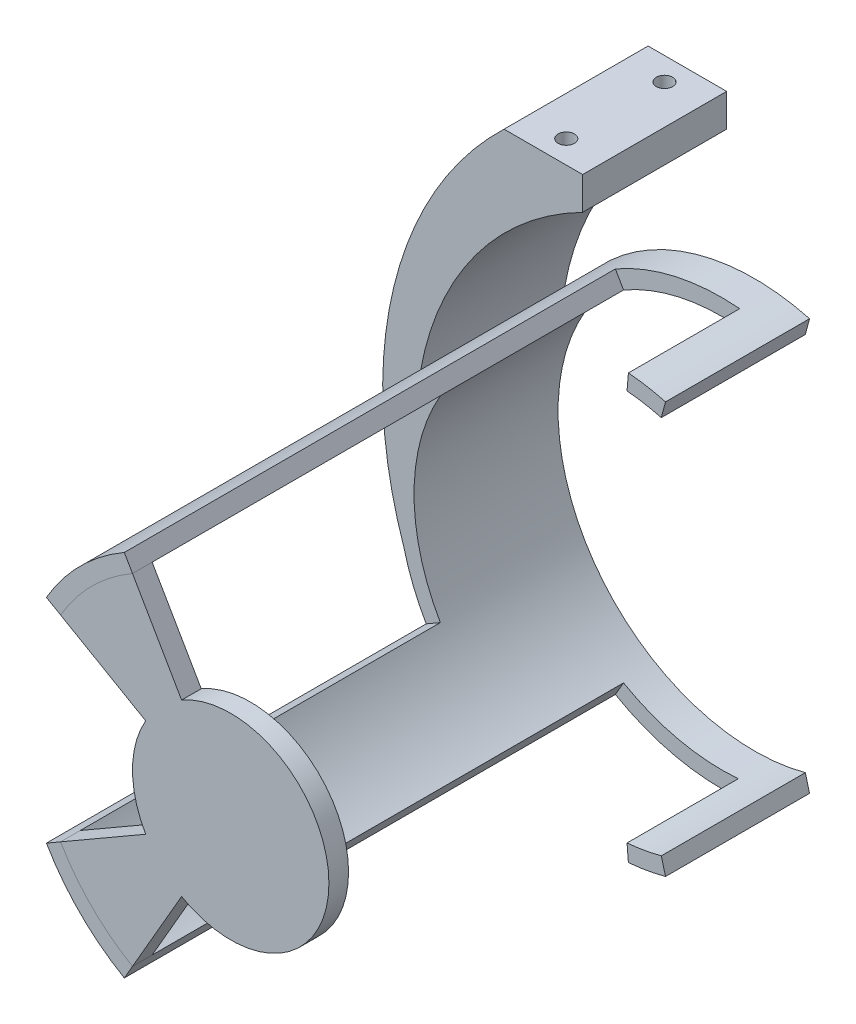
from build123d import *

# Parameters (mm, degrees)
ESQUISSE1_R                  = 32.5
ESQUISSE1_R_2                = 30
BOSS_EXTRU_1_DEPTH           = 22
BOSS_EXTRU_2_DEPTH           = 58
BOSS_EXTRU_3_START           = -77
BOSS_EXTRU_3_DEPTH           = 3
BOSS_EXTRU_4_DEPTH           = 22
ENL_V_MAT_EXTRU_1_DEPTH      = 22
ENL_V_START                  = -5
ENL_V_MAT_EXTRU_3_DEPTH      = 52
ESQUISSE9_R                  = 1.25
ENL_V_MAT_EXTRU_4_DEPTH      = 4
ENL_V_MAT_EXTRU_5_REACH      = 122.85
ENL_V_MAT_EXTRU_5_END_RADIUS = 46.665875386
ESQUISSE10_R                 = 2.5


with BuildPart() as part:
    # Esquisse1 → Boss.-Extru.1 (new body)
    with BuildSketch(Plane.XY):
        Circle(ESQUISSE1_R)
        Circle(ESQUISSE1_R_2, mode=Mode.SUBTRACT)
    extrude(amount=BOSS_EXTRU_1_DEPTH)

    # Esquisse2 → Boss.-Extru.2 (add)
    with BuildSketch(Plane.XY.offset(22)):
        with BuildLine():
            Line((-16.25, 28.145825623), (-15, 25.980762114))
            ThreePointArc((-15, 25.980762114), (-21.213203436, 21.213203436), (-25.980762114, 15))
            Line((-25.980762114, 15), (-28.145825623, 16.25))
            ThreePointArc((-28.145825623, 16.25), (-22.980970389, 22.980970389), (-16.25, 28.145825623))
        make_face()
        with BuildLine():
            Line((-28.145825623, -16.25), (-25.980762114, -15))
            ThreePointArc((-25.980762114, -15), (-21.213203436, -21.213203436), (-15, -25.980762114))
            Line((-15, -25.980762114), (-16.25, -28.145825623))
            ThreePointArc((-16.25, -28.145825623), (-22.980970389, -22.980970389), (-28.145825623, -16.25))
        make_face()
    extrude(amount=BOSS_EXTRU_2_DEPTH)

    # Esquisse5 → Boss.-Extru.4 (add)
    with BuildSketch(Plane(origin=(0, 0, 0), x_dir=(-1, 0, 0), z_dir=(0, 0, -1))):
        with BuildLine():
            Line((4.25, 50.131720502), (4.25, 55.131720502))
            Line((4.25, 55.131720502), (16.25, 55.131720502))
            ThreePointArc((16.25, 55.131720502), (33.096232565, 25.843443716), (31.523352961, -7.907478619))
            ThreePointArc((31.523352961, -7.907478619), (32.352628695, 3.091507158), (29.455329215, 13.734394083))
            ThreePointArc((29.455329215, 13.734394083), (21.443712719, 35.112380899), (4.25, 50.131720502))
        make_face()
    extrude(amount=-BOSS_EXTRU_4_DEPTH)

    # Esquisse6 → Enlèv. mat.-Extru.1 (cut)
    with BuildSketch(Plane(origin=(0, 0, 0), x_dir=(-1, 0, 0), z_dir=(0, 0, -1))):
        Polygon((0, 0), (-10.262824663, -38.301383073), (-52.320818682, 0), (-10.262824663, 38.301383073), align=None)
    extrude(amount=-ENL_V_MAT_EXTRU_1_DEPTH, mode=Mode.SUBTRACT)

    # Esquisse8 → Enlèv. mat.-Extru.3 (cut)
    with BuildSketch(Plane(origin=(0, 0, 0), x_dir=(-1, 0, 0), z_dir=(0, 0, -1)).offset(ENL_V_START)):
        with BuildLine():
            Line((-2.740791097, 32.384225545), (-1.521870682, 17.981889782))
            Line((-1.521870682, 17.981889782), (8.380077244, 14.514719558))
            Line((8.380077244, 14.514719558), (16.25, 28.145825623))
            ThreePointArc((16.25, 28.145825623), (7.079243588, 31.719620272), (-2.740791097, 32.384225545))
        make_face()
        with BuildLine():
            Line((-2.740791097, -32.384225545), (-1.521870682, -17.981889782))
            Line((-1.521870682, -17.981889782), (8.380077244, -14.514719558))
            Line((8.380077244, -14.514719558), (16.25, -28.145825623))
            ThreePointArc((16.25, -28.145825623), (7.079243588, -31.719620272), (-2.740791097, -32.384225545))
        make_face()
    extrude(amount=-ENL_V_MAT_EXTRU_3_DEPTH, mode=Mode.SUBTRACT)

    # Esquisse9 → Enlèv. mat.-Extru.4 (cut)
    with BuildSketch(Plane(origin=(0, 55.131720502, 0), x_dir=(1, 0, 0), z_dir=(0, 1, 0))):
        with Locations(Location((-10.25, -3.5, 0), (0, 0, 270))):
            Circle(ESQUISSE9_R)
        with Locations(Location((-10.25, -18.5, 0), (0, 0, 270))):
            Circle(ESQUISSE9_R)
    extrude(amount=-ENL_V_MAT_EXTRU_4_DEPTH, mode=Mode.SUBTRACT)

    # Enlèv. mat.-Extru.5: up to this cylinder (the profile starts outside it)
    enl_v_mat_extru_5_end = Plane(origin=(16.921063344, 8.544583039, 11), z_dir=(0, 0, -1)) * Cylinder(ENL_V_MAT_EXTRU_5_END_RADIUS, 355.031750771, mode=Mode.PRIVATE)
    # Esquisse10 → Enlèv. mat.-Extru.5 (cut, up to the surface)
    with BuildSketch(Plane(origin=(0, 51.131720502, 0), x_dir=(1, 0, 0), z_dir=(0, 1, 0)), mode=Mode.PRIVATE) as enl_v_mat_extru_5_sk1:
        with Locations(Location((-10.25, -3.5, 0), (0, 0, 270))):
            Circle(ESQUISSE10_R)
    enl_v_mat_extru_5_tool1 = extrude(enl_v_mat_extru_5_sk1.sketch, amount=-ENL_V_MAT_EXTRU_5_REACH, mode=Mode.PRIVATE) - enl_v_mat_extru_5_end
    add(enl_v_mat_extru_5_tool1.solids().sort_by_distance((-10.25, 51.131721, 3.5))[0], mode=Mode.SUBTRACT)
    # Esquisse10 → Enlèv. mat.-Extru.5 (cut, up to the surface)
    with BuildSketch(Plane(origin=(0, 51.131720502, 0), x_dir=(1, 0, 0), z_dir=(0, 1, 0)), mode=Mode.PRIVATE) as enl_v_mat_extru_5_sk2:
        with Locations(Location((-10.25, -18.5, 0), (0, 0, 270))):
            Circle(ESQUISSE10_R)
    enl_v_mat_extru_5_tool2 = extrude(enl_v_mat_extru_5_sk2.sketch, amount=-ENL_V_MAT_EXTRU_5_REACH, mode=Mode.PRIVATE) - enl_v_mat_extru_5_end
    add(enl_v_mat_extru_5_tool2.solids().sort_by_distance((-10.25, 51.131721, 18.5))[0], mode=Mode.SUBTRACT)


with BuildPart() as body_2:
    # Esquisse3 → Boss.-Extru.3 (new body)
    with BuildSketch(Plane(origin=(0, 0, 0), x_dir=(-1, 0, 0), z_dir=(0, 0, -1)).offset(BOSS_EXTRU_3_START)):
        with BuildLine():
            ThreePointArc((12.990381057, -7.5), (15, 0), (12.990381057, 7.5))
            Line((12.990381057, 7.5), (25.980762114, 15))
            ThreePointArc((25.980762114, 15), (21.213203436, 21.213203436), (15, 25.980762114))
            Line((15, 25.980762114), (7.5, 12.990381057))
            ThreePointArc((7.5, 12.990381057), (-15, 0), (7.5, -12.990381057))
            Line((7.5, -12.990381057), (15, -25.980762114))
            ThreePointArc((15, -25.980762114), (21.213203436, -21.213203436), (25.980762114, -15))
            Line((25.980762114, -15), (12.990381057, -7.5))
        make_face()
    extrude(amount=-BOSS_EXTRU_3_DEPTH)


solid = Compound([part.part, body_2.part])
